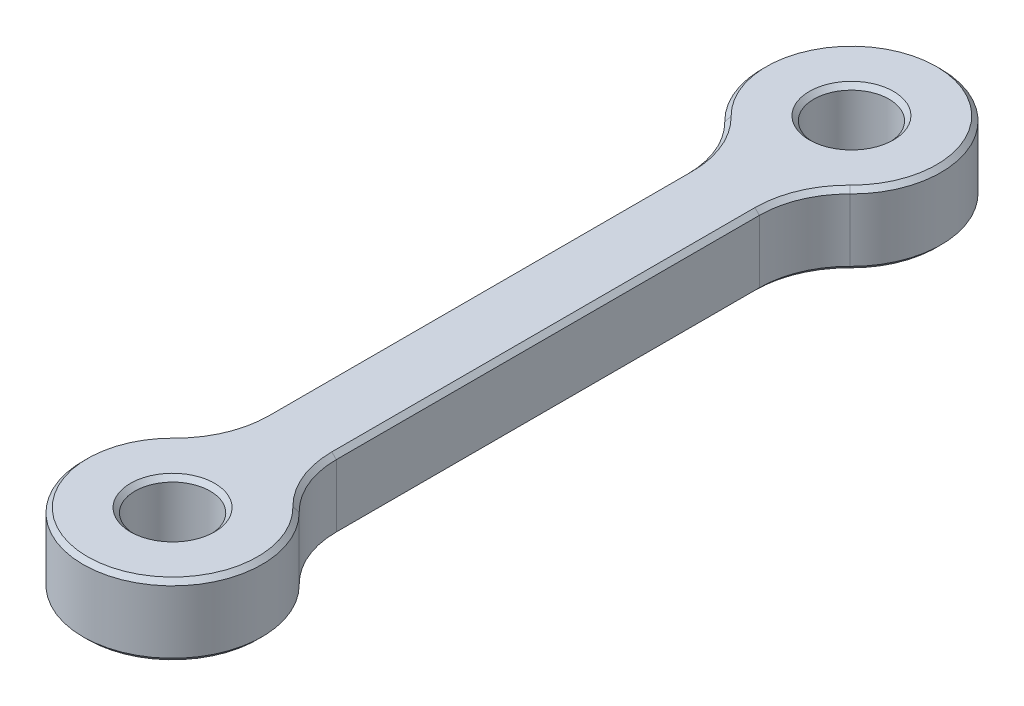
from build123d import *

# Parameters (mm, degrees)
SKETCH1_R           = 4.2
BOSS_EXTRUDE1_DEPTH = 8
FILLET1_R           = 10
CHAMFER1_SIZE       = 0.5


with BuildPart() as part:
    # Sketch1 → Boss-Extrude1 (new body)
    with BuildSketch(Plane(origin=(0, 0, 0), x_dir=(1, 0, 0), z_dir=(0, 1, 0))):
        with BuildLine():
            Line((-4, 28.73484861), (-4, -28.73484861))
            ThreePointArc((-4, -28.73484861), (0, -47.9), (4, -28.73484861))
            Line((4, -28.73484861), (4, 28.73484861))
            ThreePointArc((4, 28.73484861), (0, 47.9), (-4, 28.73484861))
        make_face()
        with Locations((0, 37.9)):
            Circle(SKETCH1_R, mode=Mode.SUBTRACT)
        with Locations((0, -37.9)):
            Circle(SKETCH1_R, mode=Mode.SUBTRACT)
    extrude(amount=BOSS_EXTRUDE1_DEPTH)

    # Fillet1
    fillet1_edges = [part.edges().sort_by_distance(p)[0] for p in [
        (4, 4, -28.73484861),
        (4, 4, 28.73484861),
        (-4, 4, 28.73484861),
        (-4, 4, -28.73484861),
    ]]
    fillet(fillet1_edges, radius=FILLET1_R)

    # Chamfer1
    chamfer1_edges = [part.edges().sort_by_distance(p)[0] for p in [
        (-4.2, 0, -37.9),
        (-4.2, 8, -37.9),
        (-4.2, 0, 37.9),
        (-4.2, 8, 37.9),
        (4, 0, 0),
        (4, 8, 0),
        (0, 0, 47.9),
        (0, 8, 47.9),
        (0, 0, -47.9),
        (0, 8, -47.9),
        (-4, 0, 0),
        (-4, 8, 0),
        (4.780455543, 0, 27.490126489),
        (4.780455543, 8, 27.490126489),
        (4.780455543, 0, -27.490126489),
        (4.780455543, 8, -27.490126489),
        (-4.780455543, 0, -27.490126489),
        (-4.780455543, 8, -27.490126489),
        (-4.780455543, 0, 27.490126489),
        (-4.780455543, 8, 27.490126489),
    ]]
    chamfer(chamfer1_edges, length=CHAMFER1_SIZE)


solid = part.part
